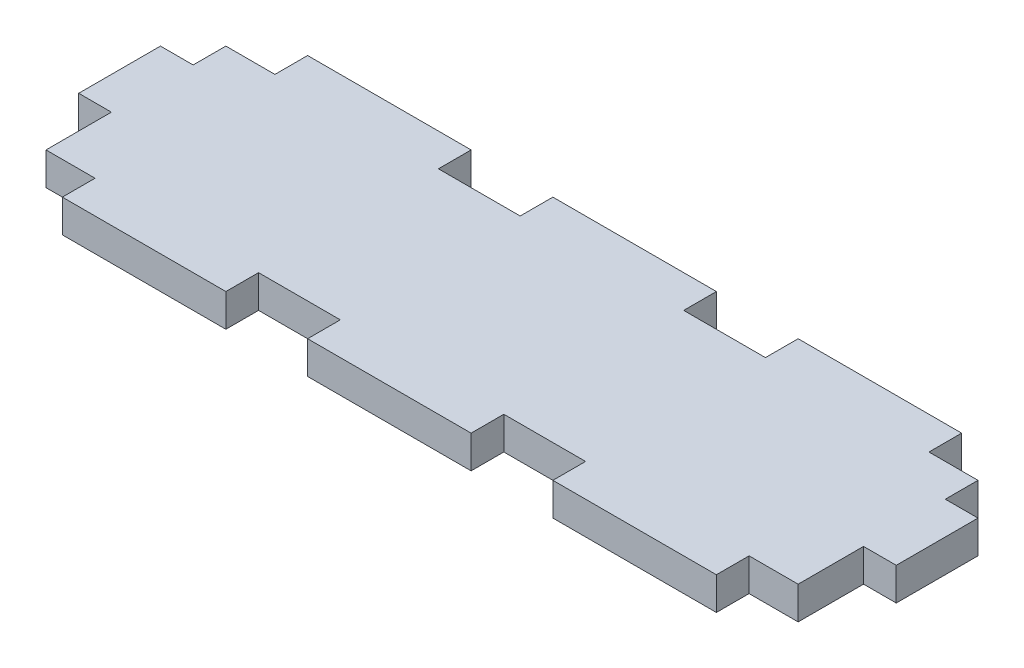
from build123d import *

# Parameters (mm, degrees)
SKETCH1_W           = 127
SKETCH1_H           = 38.1
BOSS_EXTRUDE1_DEPTH = 2.54
SKETCH2_W           = 5.08
SKETCH2_H           = 10.16
SKETCH2_H_2         = 15.24
CUT_EXTRUDE1_DEPTH  = 5.08
SKETCH3_W           = 12.7
SKETCH3_H           = 5.08
CUT_EXTRUDE2_DEPTH  = 5.08
SKETCH4_W           = 12.7
SKETCH4_H           = 5.08
CUT_EXTRUDE4_DEPTH  = 5.08
LPATTERN1_COUNT     = 2
LPATTERN1_PITCH     = 38.1
SKETCH7_W           = 116.84
SKETCH7_H           = 5.08
CUT_EXTRUDE7_DEPTH  = 5.08
SKETCH8_W           = 25.4
SKETCH8_H           = 5.08
BOSS_EXTRUDE2_DEPTH = 5.08


with BuildPart() as part:
    # Sketch1 → Boss-Extrude1 (new body, symmetric)
    with BuildSketch(Plane(origin=(0, 0, 0), x_dir=(1, 0, 0), z_dir=(0, 1, 0))):
        Rectangle(SKETCH1_W, SKETCH1_H)
    extrude(amount=BOSS_EXTRUDE1_DEPTH, both=True)

    # Sketch2 → Cut-Extrude1 (cut)
    with BuildSketch(Plane(origin=(0, 2.54, 0), x_dir=(1, 0, 0), z_dir=(0, 1, 0))):
        with Locations((-60.96, 13.97)):
            Rectangle(SKETCH2_W, SKETCH2_H)
        with Locations((-60.96, -11.43)):
            Rectangle(SKETCH2_W, SKETCH2_H_2)
    cut_extrude1 = extrude(amount=-CUT_EXTRUDE1_DEPTH, mode=Mode.SUBTRACT)

    # Mirror1: Cut-Extrude1 across plane
    add(cut_extrude1.mirror(Plane(origin=(0, 0, 0), x_dir=(0, 0, 1), z_dir=(1, 0, 0))), mode=Mode.SUBTRACT)

    # Sketch3 → Cut-Extrude2 (cut)
    with BuildSketch(Plane(origin=(0, 2.54, 0), x_dir=(1, 0, 0), z_dir=(0, 1, 0))):
        with Locations((-57.15, -16.51)):
            Rectangle(SKETCH3_W, SKETCH3_H)
    cut_extrude2 = extrude(amount=-CUT_EXTRUDE2_DEPTH, mode=Mode.SUBTRACT)

    # Mirror2: Cut-Extrude2 across plane
    add(cut_extrude2.mirror(Plane(origin=(0, 0, 0), x_dir=(0, 0, 1), z_dir=(1, 0, 0))), mode=Mode.SUBTRACT)

    # Sketch4 → Cut-Extrude4 (cut)
    with BuildSketch(Plane(origin=(0, 2.54, 0), x_dir=(1, 0, 0), z_dir=(0, 1, 0))):
        with Locations((-19.05, -16.51)):
            Rectangle(SKETCH4_W, SKETCH4_H)
    cut_extrude4 = extrude(amount=-CUT_EXTRUDE4_DEPTH, mode=Mode.SUBTRACT)

    # LPattern1: Cut-Extrude4 ×2
    with Locations(*[(i * LPATTERN1_PITCH, 0, 0) for i in range(1, LPATTERN1_COUNT)]):
        add(cut_extrude4, mode=Mode.SUBTRACT)

    # Sketch7 → Cut-Extrude7 (cut)
    with BuildSketch(Plane(origin=(0, 2.54, 0), x_dir=(1, 0, 0), z_dir=(0, 1, 0))):
        with Locations((0, 16.51)):
            Rectangle(SKETCH7_W, SKETCH7_H)
    extrude(amount=-CUT_EXTRUDE7_DEPTH, mode=Mode.SUBTRACT)

    # Sketch8 → Boss-Extrude2 (add)
    with BuildSketch(Plane(origin=(0, 2.54, 0), x_dir=(1, 0, 0), z_dir=(0, 1, 0))):
        with Locations((-38.1, 16.51)):
            Rectangle(SKETCH8_W, SKETCH8_H)
        with Locations((0, 16.51)):
            Rectangle(SKETCH8_W, SKETCH8_H)
        with Locations((38.1, 16.51)):
            Rectangle(SKETCH8_W, SKETCH8_H)
    extrude(amount=-BOSS_EXTRUDE2_DEPTH)


solid = part.part
